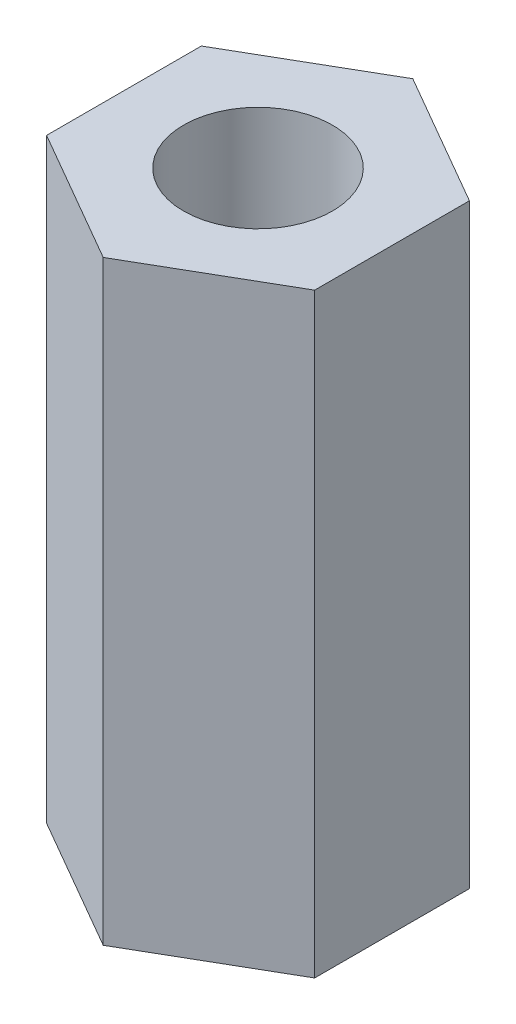
from build123d import *

# Parameters (mm, degrees)
EXTRUDE_1_DEPTH     = 5
SKETCH_2_R          = 1.25
CUT_EXTRUDE_1_DEPTH = 5


with BuildPart() as part:
    # 草图1 → 凸台-拉伸1 (new body, symmetric)
    with BuildSketch(Plane(origin=(0, 0, 0), x_dir=(1, 0, 0), z_dir=(0, 1, 0))):
        Polygon((0, -2.598076211), (2.25, -1.299038106), (2.25, 1.299038106), (0, 2.598076211), (-2.25, 1.299038106), (-2.25, -1.299038106), align=None)
    extrude(amount=EXTRUDE_1_DEPTH, both=True)

    # 草图2 → 切除-拉伸1 (cut)
    with BuildSketch(Plane(origin=(0, 5, 0), x_dir=(1, 0, 0), z_dir=(0, 1, 0))):
        Circle(SKETCH_2_R)
    extrude(amount=-CUT_EXTRUDE_1_DEPTH, mode=Mode.SUBTRACT)


solid = part.part
